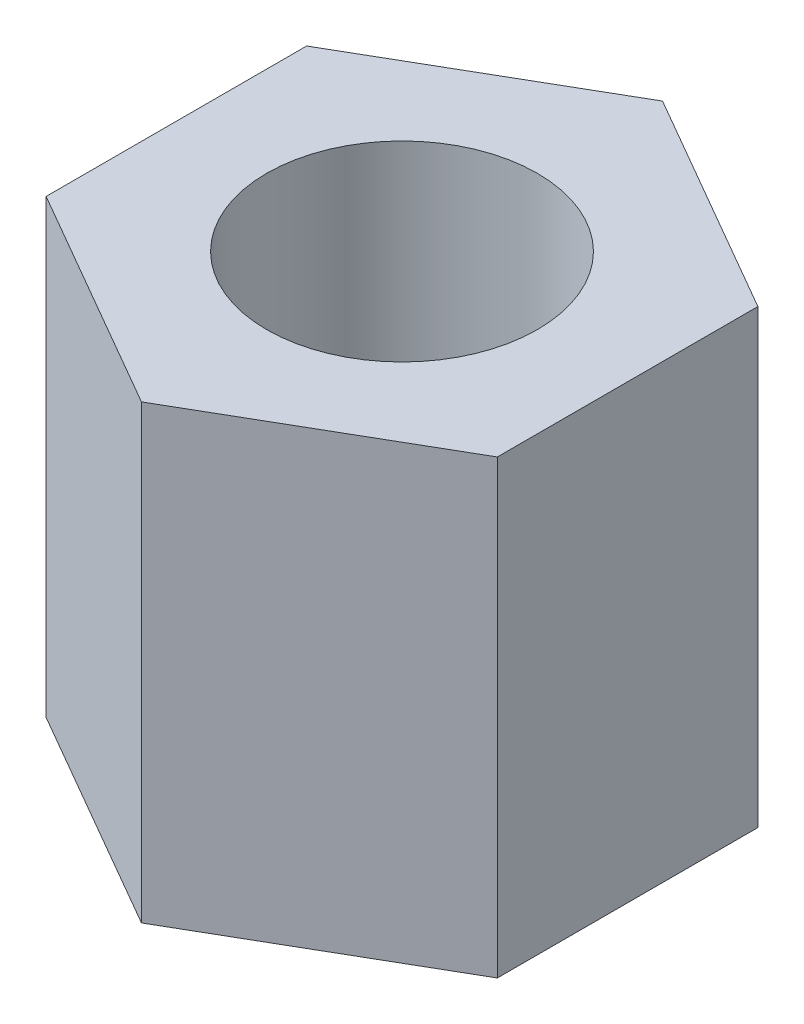
from build123d import *

# Parameters (mm, degrees)
SKETCH1_R           = 1.5
BOSS_EXTRUDE1_DEPTH = 5


with BuildPart() as part:
    # Sketch1 → Boss-Extrude1 (new body)
    with BuildSketch(Plane(origin=(0, 0, 0), x_dir=(1, 0, 0), z_dir=(0, 1, 0))):
        Polygon((-34.951809206, 17.093781707), (-37.451809206, 15.650406034), (-37.451809206, 12.763654688), (-34.951809206, 11.320279015), (-32.451809206, 12.763654688), (-32.451809206, 15.650406034), align=None)
        with Locations((-34.951809206, 14.207030361)):
            Circle(SKETCH1_R, mode=Mode.SUBTRACT)
    extrude(amount=BOSS_EXTRUDE1_DEPTH)


solid = part.part
